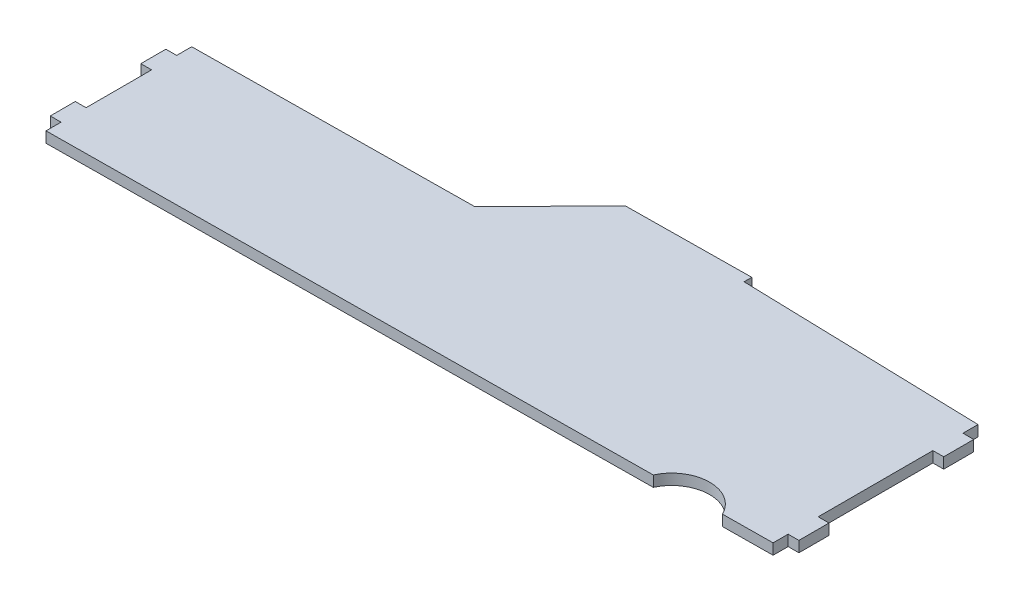
from build123d import *

# Parameters (mm, degrees)
BOSS_EXTRUDE1_DEPTH = 4.3


with BuildPart() as part:
    # Sketch4 → Boss-Extrude1 (new body)
    with BuildSketch(Plane(origin=(0, 0, 0), x_dir=(1, 0, 0), z_dir=(0, 1, 0))):
        with BuildLine():
            Line((47.736880922, -13.610395438), (47.736880922, -10.518490221))
            Line((47.736880922, -10.518490221), (-2.263119078, -11.062941575))
            Line((-2.263119078, -11.062941575), (-31.934689225, -41.387814618))
            Line((-31.934689225, -41.387814618), (-143.77908283, -42.60569125))
            Line((-143.77908283, -42.60569125), (-143.77908283, -48.60569125))
            Line((-143.77908283, -48.60569125), (-148.07908283, -48.60569125))
            Line((-148.07908283, -48.60569125), (-148.07908283, -58.60569125))
            Line((-148.07908283, -58.60569125), (-143.77908283, -58.60569125))
            Line((-143.77908283, -58.60569125), (-143.77908283, -84.761876256))
            Line((-143.77908283, -84.761876256), (-148.07908283, -84.761876256))
            Line((-148.07908283, -84.761876256), (-148.07908283, -94.761876256))
            Line((-148.07908283, -94.761876256), (-143.77908283, -94.761876256))
            Line((-143.77908283, -94.761876256), (-143.77908283, -100.761876256))
            Line((-143.77908283, -100.761876256), (96.389605884, -98.512277012))
            ThreePointArc((96.389605884, -98.512277012), (109.998414099, -89.747620618), (123.769012787, -98.255821046))
            Line((123.769012787, -98.255821046), (143.77908283, -98.068391791))
            Line((143.77908283, -98.068391791), (143.77908283, -92.068391791))
            Line((143.77908283, -92.068391791), (148.07908283, -92.068391791))
            Line((148.07908283, -92.068391791), (148.07908283, -80.068391791))
            Line((148.07908283, -80.068391791), (143.77908283, -80.068391791))
            Line((143.77908283, -80.068391791), (143.77908283, -34.269759798))
            Line((143.77908283, -34.269759798), (148.07908283, -34.269759798))
            Line((148.07908283, -34.269759798), (148.07908283, -22.269759798))
            Line((148.07908283, -22.269759798), (143.77908283, -22.269759798))
            Line((143.77908283, -22.269759798), (143.77908283, -16.269759798))
            Line((143.77908283, -16.269759798), (47.736880922, -13.610395438))
        make_face()
    extrude(amount=-BOSS_EXTRUDE1_DEPTH)


solid = part.part
